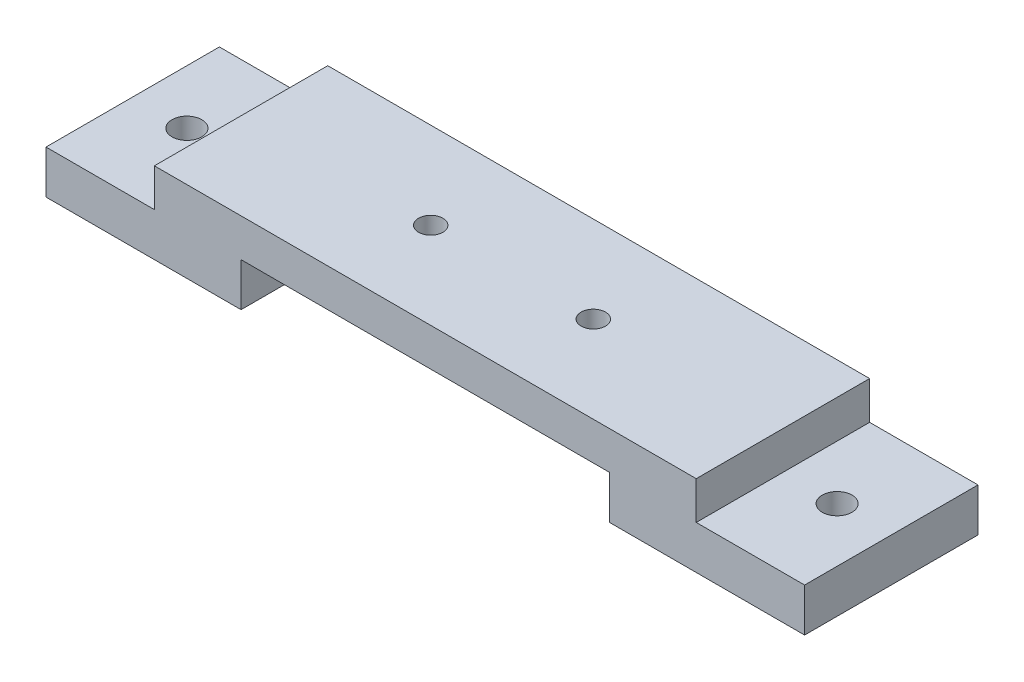
from build123d import *

# Parameters (mm, degrees)
AUFSATZ_LINEAR_AUSTRAGEN1_DEPTH  = 32
F_4_5_4_5_DURCHMESSER_BOHRUNG1_D = 4.5
F_5_5_5_5_DURCHMESSER_BOHRUNG1_D = 5.5


with BuildPart() as part:
    # Skizze1 → Aufsatz-Linear austragen1 (new body)
    with BuildSketch(Plane.XY):
        Polygon((-70, 20), (-34, 20), (-34, 28), (34, 28), (34, 20), (70, 20), (70, 28), (50, 28), (50, 35), (-50, 35), (-50, 28), (-70, 28), align=None)
    extrude(amount=-AUFSATZ_LINEAR_AUSTRAGEN1_DEPTH)

    # Ø4.5 (4.5) Durchmesser Bohrung1 (through all)
    with Locations(Plane(origin=(-15, 28, -16), x_dir=(0, 0, -1), z_dir=(0, -1, 0))):
        with Locations((0, 0), (0, 30)):
            Hole(F_4_5_4_5_DURCHMESSER_BOHRUNG1_D / 2)

    # Ø5.5 (5.5) Durchmesser Bohrung1 (through all)
    with Locations(Plane(origin=(-60, 28, -16), x_dir=(1, 0, 0), z_dir=(0, 1, 0))):
        with Locations((0, 0), (120, 0)):
            Hole(F_5_5_5_5_DURCHMESSER_BOHRUNG1_D / 2)


solid = part.part
